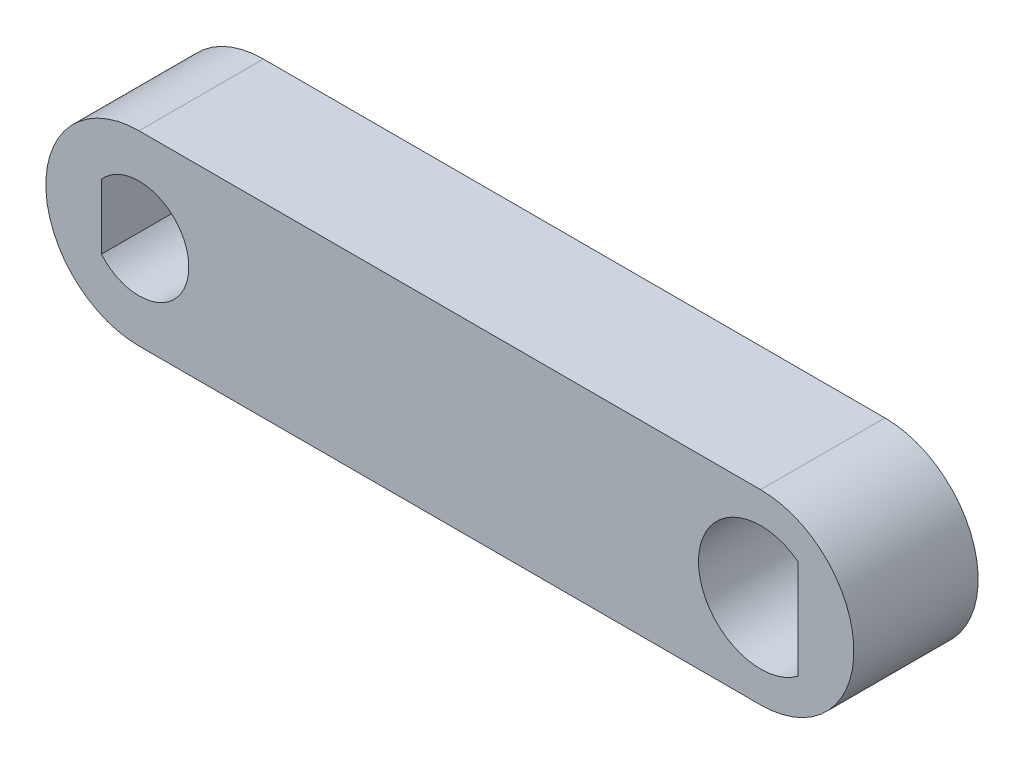
from build123d import *

# Parameters (mm, degrees)
Y_KSEKLIK_EKSTR_ZYON1_DEPTH = 10


with BuildPart() as part:
    # Çizim1 → Yükseklik-Ekstrüzyon1 (new body)
    with BuildSketch(Plane.XY):
        with BuildLine():
            Line((0, 7.5), (50, 7.5))
            ThreePointArc((50, 7.5), (57.5, 0), (50, -7.5))
            Line((50, -7.5), (0, -7.5))
            ThreePointArc((0, -7.5), (-7.5, 0), (0, 7.5))
        make_face()
        with BuildLine():
            Line((53, 4), (53, -4))
            ThreePointArc((53, -4), (45, 0), (53, 4))
        make_face(mode=Mode.SUBTRACT)
        with BuildLine():
            Line((-3.029770917, 2.611606439), (-3.029770917, -2.611606439))
            ThreePointArc((-3.029770917, -2.611606439), (4, 0), (-3.029770917, 2.611606439))
        make_face(mode=Mode.SUBTRACT)
    extrude(amount=Y_KSEKLIK_EKSTR_ZYON1_DEPTH)


solid = part.part
